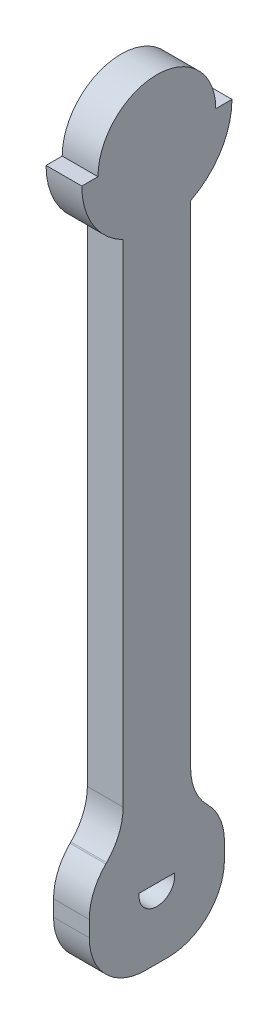
from build123d import *

# Parameters (mm, degrees)
BOSS_EXTRUDE1_DEPTH = 6.35
FILLET1_R           = 10


with BuildPart() as part:
    # Sketch1 → Boss-Extrude1 (new body)
    with BuildSketch(Plane(origin=(0, 0, 0), x_dir=(0, 0, -1), z_dir=(1, 0, 0))):
        with BuildLine():
            Line((-6, 108.391086322), (-6, 16.970562748))
            Line((-6, 16.970562748), (-12, 10.970562748))
            Line((-12, 10.970562748), (-12, -6))
            Line((-12, -6), (12, -6))
            Line((12, -6), (12, 10.970562748))
            Line((12, 10.970562748), (6, 16.970562748))
            Line((6, 16.970562748), (6, 108.391086322))
            ThreePointArc((6, 108.391086322), (11.35412315, 113.306709465), (13.335, 120.3))
            Line((13.335, 120.3), (10.4648, 120.3))
            ThreePointArc((10.4648, 120.3), (0, 130.7648), (-10.4648, 120.3))
            Line((-10.4648, 120.3), (-13.335, 120.3))
            ThreePointArc((-13.335, 120.3), (-11.35412315, 113.306709465), (-6, 108.391086322))
        make_face()
        with BuildLine():
            Line((-3.146426545, 6.425), (3.146426545, 6.425))
            ThreePointArc((3.146426545, 6.425), (0, 2.825), (-3.146426545, 6.425))
        make_face(mode=Mode.SUBTRACT)
    extrude(amount=BOSS_EXTRUDE1_DEPTH)

    # Fillet1
    fillet1_edges = [part.edges().sort_by_distance(p)[0] for p in [
        (3.175, 16.970562748, -6),
        (3.175, 10.970562748, -12),
        (3.175, -6, -12),
        (3.175, -6, 12),
        (3.175, 10.970562748, 12),
        (3.175, 16.970562748, 6),
    ]]
    fillet(fillet1_edges, radius=FILLET1_R)


solid = part.part
